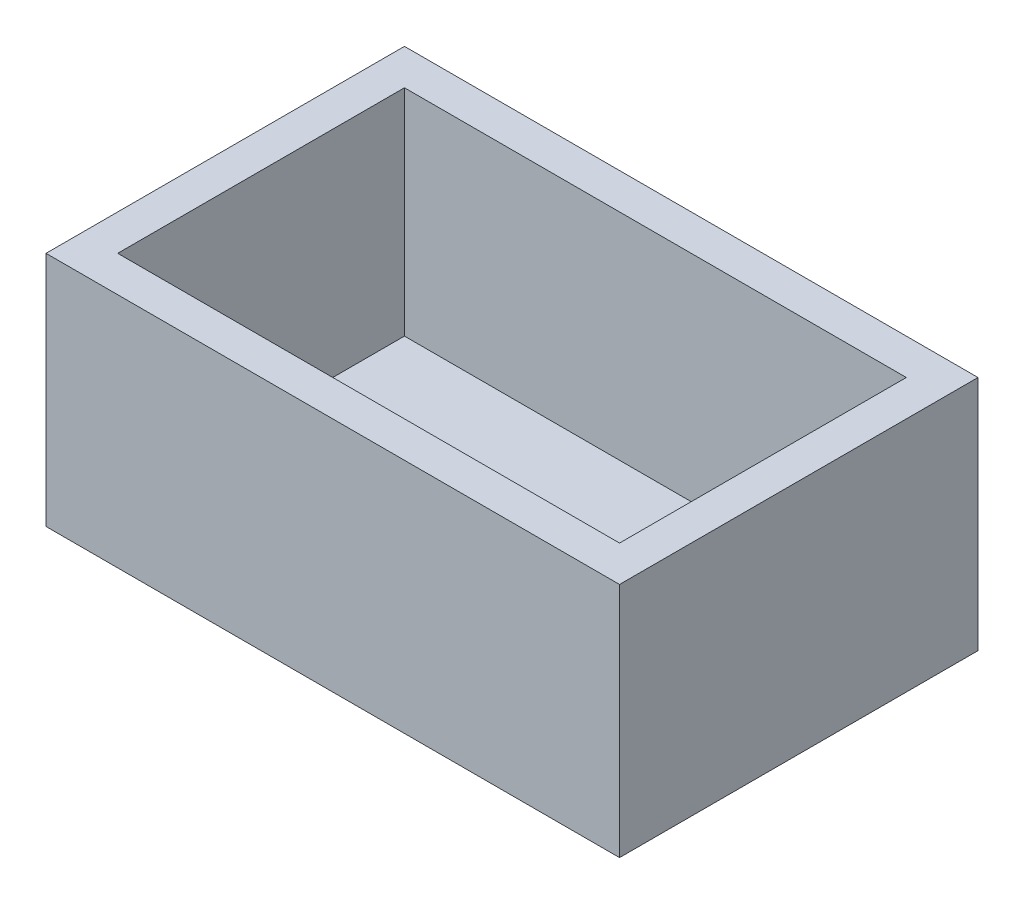
from build123d import *

# Parameters (mm, degrees)
SKETCH1_W           = 80
SKETCH1_H           = 50
BOSS_EXTRUDE1_DEPTH = 3
SKETCH2_W           = 80
SKETCH2_H           = 50
SKETCH2_W_2         = 70
SKETCH2_H_2         = 40
BOSS_EXTRUDE2_DEPTH = 30


with BuildPart() as part:
    # Sketch1 → Boss-Extrude1 (new body)
    with BuildSketch(Plane(origin=(0, 0, 0), x_dir=(1, 0, 0), z_dir=(0, 1, 0))):
        Rectangle(SKETCH1_W, SKETCH1_H)
    extrude(amount=BOSS_EXTRUDE1_DEPTH)

    # Sketch2 → Boss-Extrude2 (add)
    with BuildSketch(Plane(origin=(0, 3, 0), x_dir=(1, 0, 0), z_dir=(0, 1, 0))):
        Rectangle(SKETCH2_W, SKETCH2_H)
        Rectangle(SKETCH2_W_2, SKETCH2_H_2, mode=Mode.SUBTRACT)
    extrude(amount=BOSS_EXTRUDE2_DEPTH)


solid = part.part
